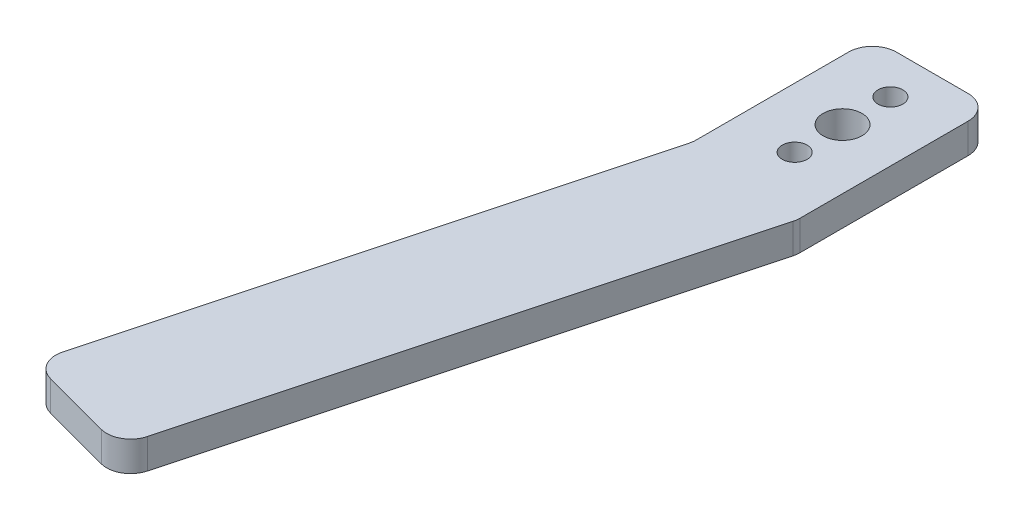
from build123d import *

# Parameters (mm, degrees)
SKETCH1_R           = 3.25
BOSS_EXTRUDE1_DEPTH = 5
CUT_EXTRUDE1_START  = -6
SKETCH2_R           = 2.075
CUT_EXTRUDE1_DEPTH  = 7
FILLET1_R           = 4


with BuildPart() as part:
    # Sketch1 → Boss-Extrude1 (new body)
    with BuildSketch(Plane(origin=(0, 0, 0), x_dir=(1, 0, 0), z_dir=(0, 1, 0))):
        Polygon((-59.15, -15), (-82.443714059, -101.933324366), (-63.125197533, -107.109705268), (-39.831483474, -20.176380902), (-39.15, -17.633049952), (-39.15, -15), (-39.15, 15), (-59.15, 15), align=None)
        with Locations((-49.15, 0)):
            Circle(SKETCH1_R, mode=Mode.SUBTRACT)
    extrude(amount=BOSS_EXTRUDE1_DEPTH)

    # Sketch2 → Cut-Extrude1 (cut)
    with BuildSketch(Plane(origin=(0, 5, 0), x_dir=(1, 0, 0), z_dir=(0, 1, 0)).offset(CUT_EXTRUDE1_START)):
        with Locations((-49.15, 8)):
            Circle(SKETCH2_R)
    cut_extrude1 = extrude(amount=CUT_EXTRUDE1_DEPTH, mode=Mode.SUBTRACT)

    # Mirror1: Cut-Extrude1 across plane
    add(cut_extrude1.mirror(Plane.XY), mode=Mode.SUBTRACT)

    # Fillet1
    fillet1_edges = [part.edges().sort_by_distance(p)[0] for p in [
        (-39.15, 2.5, 17.633049952),
        (-63.125197533, 2.5, 107.109705268),
        (-82.443714059, 2.5, 101.933324366),
        (-59.15, 2.5, 15),
        (-59.15, 2.5, -15),
        (-39.15, 2.5, -15),
    ]]
    fillet(fillet1_edges, radius=FILLET1_R)


solid = part.part
